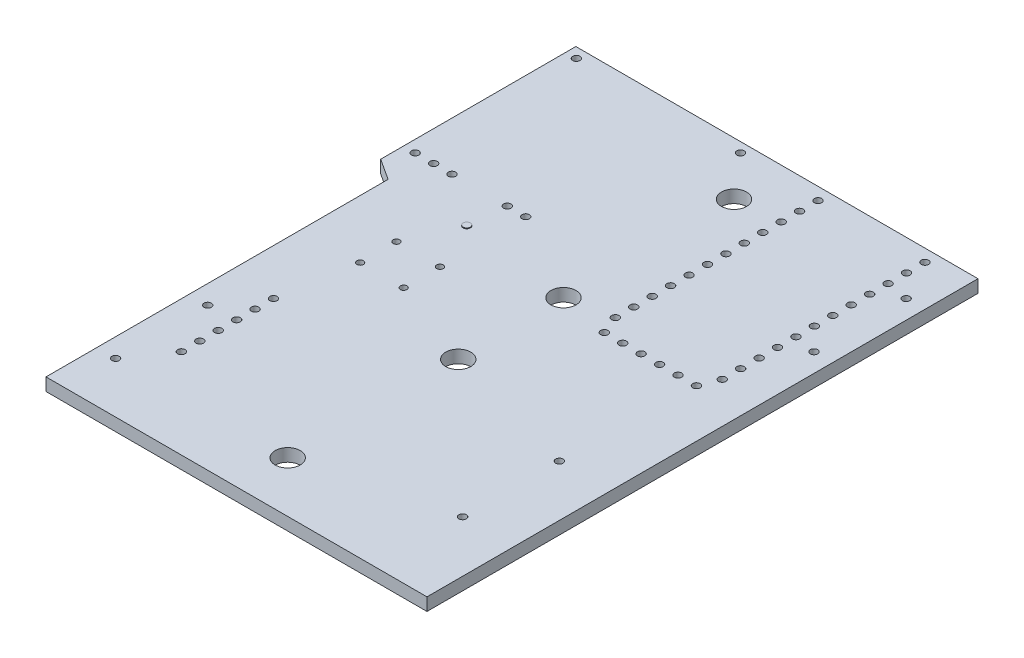
from build123d import *

# Parameters (mm, degrees)
BOSS_EXTRUDE1_DEPTH = 0.875
SKETCH2_R           = 1.7272
SKETCH2_R_2         = 0.508
CUT_EXTRUDE1_DEPTH  = 2.75
SKETCH4_R           = 0.508
CUT_EXTRUDE2_DEPTH  = 2.75
SKETCH5_R           = 0.508
CUT_EXTRUDE3_DEPTH  = 2.75
SKETCH6_R           = 0.508
CUT_EXTRUDE4_DEPTH  = 2.75
SKETCH7_R           = 0.508
CUT_EXTRUDE5_DEPTH  = 2.75
SKETCH8_R           = 0.45
CUT_EXTRUDE6_DEPTH  = 2.75
SKETCH9_R           = 0.5
BOSS_EXTRUDE2_DEPTH = 0.1


with BuildPart() as part:
    # Sketch1 → Boss-Extrude1 (new body, symmetric)
    with BuildSketch(Plane(origin=(0, 0, 0), x_dir=(1, 0, 0), z_dir=(0, 1, 0))):
        Polygon((-27.715, 37.975), (27.715, 37.975), (27.715, -37.975), (-24.795, -37.975), (-24.795, 9.175), (-27.715, 11.075), align=None)
    extrude(amount=BOSS_EXTRUDE1_DEPTH, both=True)

    # Sketch2 → Cut-Extrude1 (cut, through all)
    with BuildSketch(Plane(origin=(0, 0.875, 0), x_dir=(1, 0, 0), z_dir=(0, 1, 0))):
        with Locations((1.5194, -30.9773)):
            Circle(SKETCH2_R)
        with Locations((1.5194, -7.4696)):
            Circle(SKETCH2_R)
        with Locations((1.4133, 7.1394)):
            Circle(SKETCH2_R)
        with Locations((1.4133, 30.6471)):
            Circle(SKETCH2_R)
        with Locations((-22.2042, -30.9773)):
            Circle(SKETCH2_R_2)
        with Locations((-22.2042, -18.2773)):
            Circle(SKETCH2_R_2)
        with Locations((25.1369, 17.9471)):
            Circle(SKETCH2_R_2)
        with Locations((25.1369, 30.6471)):
            Circle(SKETCH2_R_2)
    extrude(amount=-CUT_EXTRUDE1_DEPTH, mode=Mode.SUBTRACT)

    # Sketch4 → Cut-Extrude2 (cut, through all)
    with BuildSketch(Plane(origin=(0, 0.875, 0), x_dir=(1, 0, 0), z_dir=(0, 1, 0))):
        with Locations((-18.4704, -12.9433)):
            Circle(SKETCH4_R)
        with Locations((-18.4704, -15.4833)):
            Circle(SKETCH4_R)
        with Locations((-18.4704, -18.0233)):
            Circle(SKETCH4_R)
        with Locations((-18.4704, -20.5633)):
            Circle(SKETCH4_R)
        with Locations((-18.4704, -23.1033)):
            Circle(SKETCH4_R)
        with Locations((-18.4704, -25.6433)):
            Circle(SKETCH4_R)
    extrude(amount=-CUT_EXTRUDE2_DEPTH, mode=Mode.SUBTRACT)

    # Sketch5 → Cut-Extrude3 (cut, through all)
    with BuildSketch(Plane(origin=(0, 0.875, 0), x_dir=(1, 0, 0), z_dir=(0, 1, 0))):
        with Locations((-26.0894, 14.2006)):
            Circle(SKETCH5_R)
        with Locations((-23.5494, 14.2006)):
            Circle(SKETCH5_R)
        with Locations((-21.0094, 14.2006)):
            Circle(SKETCH5_R)
        with Locations((-13.3894, 14.2006)):
            Circle(SKETCH5_R)
        with Locations((-10.8494, 14.2006)):
            Circle(SKETCH5_R)
    extrude(amount=-CUT_EXTRUDE3_DEPTH, mode=Mode.SUBTRACT)

    # Sketch6 → Cut-Extrude4 (cut, through all)
    with BuildSketch(Plane(origin=(0, 0.875, 0), x_dir=(1, 0, 0), z_dir=(0, 1, 0))):
        with Locations((7.3696, 36.2732)):
            Circle(SKETCH6_R)
        with Locations((7.3696, 33.7332)):
            Circle(SKETCH6_R)
        with Locations((7.3696, 31.1932)):
            Circle(SKETCH6_R)
        with Locations((7.3696, 28.6532)):
            Circle(SKETCH6_R)
        with Locations((7.3696, 26.1132)):
            Circle(SKETCH6_R)
        with Locations((7.3696, 23.5732)):
            Circle(SKETCH6_R)
        with Locations((7.3696, 21.0332)):
            Circle(SKETCH6_R)
        with Locations((7.3696, 18.4932)):
            Circle(SKETCH6_R)
        with Locations((7.3696, 15.9532)):
            Circle(SKETCH6_R)
        with Locations((7.3696, 13.4132)):
            Circle(SKETCH6_R)
        with Locations((7.3696, 10.8732)):
            Circle(SKETCH6_R)
        with Locations((7.3696, 8.3332)):
            Circle(SKETCH6_R)
        with Locations((8.3856, 5.7932)):
            Circle(SKETCH6_R)
        with Locations((10.9256, 5.7932)):
            Circle(SKETCH6_R)
        with Locations((13.4656, 5.7932)):
            Circle(SKETCH6_R)
        with Locations((16.0056, 5.7932)):
            Circle(SKETCH6_R)
        with Locations((18.5456, 5.7932)):
            Circle(SKETCH6_R)
        with Locations((21.0856, 5.7932)):
            Circle(SKETCH6_R)
        with Locations((22.1016, 8.3332)):
            Circle(SKETCH6_R)
        with Locations((22.1016, 10.8732)):
            Circle(SKETCH6_R)
        with Locations((22.1016, 13.4132)):
            Circle(SKETCH6_R)
        with Locations((22.1016, 15.9532)):
            Circle(SKETCH6_R)
        with Locations((22.1016, 18.4932)):
            Circle(SKETCH6_R)
        with Locations((22.1016, 21.0332)):
            Circle(SKETCH6_R)
        with Locations((22.1016, 23.5732)):
            Circle(SKETCH6_R)
        with Locations((22.1016, 26.1132)):
            Circle(SKETCH6_R)
        with Locations((22.1016, 28.6532)):
            Circle(SKETCH6_R)
        with Locations((22.1016, 31.1932)):
            Circle(SKETCH6_R)
        with Locations((22.1016, 33.7332)):
            Circle(SKETCH6_R)
        with Locations((22.1016, 36.2732)):
            Circle(SKETCH6_R)
    extrude(amount=-CUT_EXTRUDE4_DEPTH, mode=Mode.SUBTRACT)

    # Sketch7 → Cut-Extrude5 (cut, through all)
    with BuildSketch(Plane(origin=(0, 0.875, 0), x_dir=(1, 0, 0), z_dir=(0, 1, 0))):
        with Locations((20.6157, -25.9608)):
            Circle(SKETCH7_R)
        with Locations((20.6411, -12.6512)):
            Circle(SKETCH7_R)
        with Locations((-3.6612, 36.6161)):
            Circle(SKETCH7_R)
        with Locations((-26.2545, 36.5907)):
            Circle(SKETCH7_R)
    extrude(amount=-CUT_EXTRUDE5_DEPTH, mode=Mode.SUBTRACT)

    # Sketch8 → Cut-Extrude6 (cut, through all)
    with BuildSketch(Plane(origin=(0, 0.875, 0), x_dir=(1, 0, 0), z_dir=(0, 1, 0))):
        with Locations((-16.7858, 2.3183)):
            Circle(SKETCH8_R)
        with Locations((-10.7858, 2.3183)):
            Circle(SKETCH8_R)
        with Locations((-16.7858, -2.6817)):
            Circle(SKETCH8_R)
        with Locations((-10.7858, -2.6817)):
            Circle(SKETCH8_R)
    extrude(amount=-CUT_EXTRUDE6_DEPTH, mode=Mode.SUBTRACT)

    # Sketch9 → Boss-Extrude2 (add)
    with BuildSketch(Plane(origin=(0, 0.875, 0), x_dir=(1, 0, 0), z_dir=(0, 1, 0))):
        with Locations((-13.8267, 9.048)):
            Circle(SKETCH9_R)
    extrude(amount=BOSS_EXTRUDE2_DEPTH)


solid = part.part
